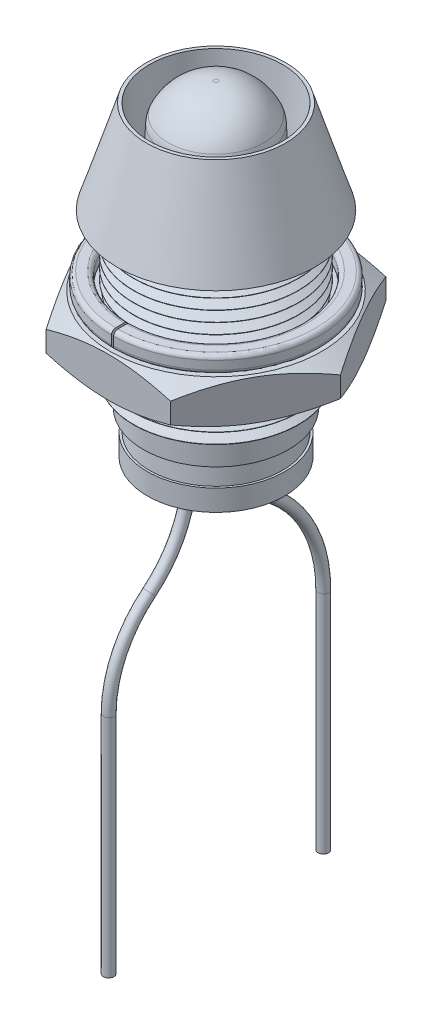
from build123d import *

# Parameters (mm, degrees)
LPATTERN1_COUNT       = 14
LPATTERN1_PITCH       = 0.5
SKETCH7_R             = 3.65
BOSS_EXTRUDE1_DEPTH   = 2
SKETCH9_R             = 4.9
SKETCH9_R_2           = 4.1
BOSS_EXTRUDE2_DEPTH   = 0.8
FILLET1_R             = 0.2
CUT_EXTRUDE4_START    = -2.8
SKETCH10_W            = 0.1
SKETCH10_H            = 2
CUT_EXTRUDE4_DEPTH    = 2.8
SKETCH12_R            = 2.45
CUT_EXTRUDE5_DEPTH    = 4.8
SKETCH13_W            = 0.8
SKETCH13_H            = 0.8
CUT_EXTRUDE6_DEPTH    = 2
SKETCH14_R            = 0.75
CUT_EXTRUDE7_DEPTH    = 0.1
CUT_EXTRUDE9_DEPTH    = 0.01
CUT_EXTRUDE8_DEPTH    = 1.2
SKETCH_WIRE_PROFILE_R = 0.25


with BuildPart() as part:
    # Sketch1 → Revolve1 (revolve)
    with BuildSketch(Plane.XY, mode=Mode.PRIVATE) as revolve1_sk:
        Polygon((0, 0), (0, 12.5), (3.3, 12.5), (4.68, 8.1), (3.9, 8.1), (3.9, 1), (3.44, 1), (3.44, 0), align=None)
    revolve(revolve1_sk.sketch.rotate(Axis((0, 0, 0), (0, 1, 0)), 90), axis=Axis((0, 0, 0), (0, 1, 0)))

    # Sketch6 → Cut-Revolve2 (revolve, cut)
    with BuildSketch(Plane.XY, mode=Mode.PRIVATE) as cut_revolve2_sk:
        Polygon((0, 0), (0, 12.5), (3.15, 12.5), (2.65, 5.8), (3.05, 5.8), (3.05, 0), align=None)
    revolve(cut_revolve2_sk.sketch.rotate(Axis((0, 0, 0), (0, 1, 0)), 90), axis=Axis((0, 0, 0), (0, 1, 0)), mode=Mode.SUBTRACT)

    # Sketch5 → Cut-Revolve1 (revolve, cut)
    with BuildSketch(Plane.XY, mode=Mode.PRIVATE) as cut_revolve1_sk:
        Polygon((4.413012702, 1.25), (4.413012702, 0.75), (3.913012702, 0.75), (3.48, 1), (3.913012702, 1.25), align=None)
    cut_revolve1 = revolve(cut_revolve1_sk.sketch.rotate(Axis((0, 0, 0), (0, 1, 0)), 90), axis=Axis((0, 0, 0), (0, 1, 0)), mode=Mode.SUBTRACT)

    # LPattern1: Cut-Revolve1 ×14
    with Locations(*[(0, i * LPATTERN1_PITCH, 0) for i in range(1, LPATTERN1_COUNT)]):
        add(cut_revolve1, mode=Mode.SUBTRACT)


with BuildPart() as body_2:
    # Sketch7 → Boss-Extrude1 (new body)
    with BuildSketch(Plane(origin=(0, 4.8, 0), x_dir=(-1, 0, 0), z_dir=(0, -1, 0))):
        Polygon((-5.888972746, 0), (-2.944486373, -5.1), (2.944486373, -5.1), (5.888972746, 0), (2.944486373, 5.1), (-2.944486373, 5.1), align=None)
        with Locations(Location((0, 0, 0), (0, 0, 90))):
            Circle(SKETCH7_R, mode=Mode.SUBTRACT)
    extrude(amount=BOSS_EXTRUDE1_DEPTH)

    # Sketch8 → Cut-Revolve3 (revolve, cut)
    with BuildSketch(Plane.XY, mode=Mode.PRIVATE) as cut_revolve3_sk:
        Polygon((5, 4.8), (5.888972746, 4.8), (5.888972746, 4.286751346), align=None)
        Polygon((5, 2.8), (5.888972746, 2.8), (5.888972746, 3.313248654), align=None)
    revolve(cut_revolve3_sk.sketch.rotate(Axis((0, 2.8, 0), (0, 1, 0)), 299.999999974), axis=Axis((0, 2.8, 0), (0, 1, 0)), mode=Mode.SUBTRACT)


with BuildPart() as body_3:
    # Sketch9 → Boss-Extrude2 (new body)
    with BuildSketch(Plane(origin=(0, 4.8, 0), x_dir=(1, 0, 0), z_dir=(0, 1, 0))):
        with Locations(Location((0, 0, 0), (0, 0, 270))):
            Circle(SKETCH9_R)
        with Locations(Location((0, 0, 0), (0, 0, 270))):
            Circle(SKETCH9_R_2, mode=Mode.SUBTRACT)
    extrude(amount=BOSS_EXTRUDE2_DEPTH)

    # Fillet1
    fillet1_edges = [body_3.edges().sort_by_distance(p)[0] for p in [
        (0, 4.8, -4.9),
        (0, 5.6, -4.9),
        (0, 4.8, -4.1),
        (0, 5.6, -4.1),
    ]]
    fillet(fillet1_edges, radius=FILLET1_R)

    # Sketch10 → Cut-Extrude4 (cut)
    with BuildSketch(Plane(origin=(0, 5.6, 0), x_dir=(1, 0, 0), z_dir=(0, 1, 0)).offset(CUT_EXTRUDE4_START)):
        with Locations((0, -4.5)):
            Rectangle(SKETCH10_W, SKETCH10_H)
    extrude(amount=CUT_EXTRUDE4_DEPTH, mode=Mode.SUBTRACT)


with BuildPart() as body_4:
    # Sketch11 → Revolve2 (revolve)
    with BuildSketch(Plane.XY, mode=Mode.PRIVATE) as revolve2_sk:
        Polygon((0, 4.8), (0, -2), (3.25, -2), (3.25, -1), (3.15, -1), (2.8, 4.8), align=None)
    revolve(revolve2_sk.sketch.rotate(Axis((0, 4.8, 0), (0, 1, 0)), 90), axis=Axis((0, 4.8, 0), (0, 1, 0)))

    # Sketch12 → Cut-Extrude5 (cut)
    with BuildSketch(Plane(origin=(0, 4.8, 0), x_dir=(1, 0, 0), z_dir=(0, 1, 0))):
        with Locations(Location((0, 0, 0), (0, 0, 270))):
            Circle(SKETCH12_R)
    extrude(amount=-CUT_EXTRUDE5_DEPTH, mode=Mode.SUBTRACT)

    # Sketch13 → Cut-Extrude6 (cut)
    with BuildSketch(Plane(origin=(0, 0, 0), x_dir=(1, 0, 0), z_dir=(0, 1, 0))):
        with Locations((0, 1.27)):
            Rectangle(SKETCH13_W, SKETCH13_H)
        with Locations((0, -1.27)):
            Rectangle(SKETCH13_W, SKETCH13_H)
    extrude(amount=-CUT_EXTRUDE6_DEPTH, mode=Mode.SUBTRACT)

    # Sketch14 → Cut-Extrude7 (cut)
    with BuildSketch(Plane.XZ.offset(2)):
        with Locations(Location((0, -1.27, 0), (0, 0, 270))):
            Circle(SKETCH14_R)
        with Locations(Location((0, 1.27, 0), (0, 0, 270))):
            Circle(SKETCH14_R)
    extrude(amount=-CUT_EXTRUDE7_DEPTH, mode=Mode.SUBTRACT)

    # Sketch21 → Cut-Extrude9 (cut)
    with BuildSketch(Plane.XZ.offset(2)):
        with BuildLine():
            add(Edge.make_bspline(
                [(0.364705882, 2.263786765), (0.365912746, 2.260307351), (0.368162564, 2.253821082), (0.370714357, 2.24445712), (0.372758311, 2.236319514), (0.374151689, 2.229223622), (0.374675847, 2.223078316), (0.373899912, 2.217778193), (0.372316679, 2.21309534), (0.369179602, 2.20933953), (0.364961324, 2.206278709), (0.35935951, 2.20418994), (0.352616544, 2.202313423), (0.344448609, 2.201319849), (0.33486625, 2.200924205), (0.323782624, 2.200230338), (0.31096711, 2.200209211), (0.301899116, 2.200072809), (0.297058824, 2.2)],
                knots=[0, 0, 0, 0, 1.351975101, 2.52033068, 3.562719996, 4.432170766, 5.176088948, 5.812532786, 6.389296298, 6.965620705, 7.577732788, 8.283941723, 9.146375963, 10.145613058, 11.295182858, 12.669444765, 14.222224263, 16, 16, 16, 16], degree=3))
            add(Edge.make_bspline(
                [(0.297058824, 2.2), (0.292095654, 2.199988185), (0.282720354, 2.199965866), (0.269543114, 2.200112253), (0.258088748, 2.200552893), (0.245808258, 2.200889505), (0.233505333, 2.202060288), (0.221675289, 2.203990326), (0.213185608, 2.207223602), (0.207403537, 2.211992232), (0.204102868, 2.218299147), (0.202511149, 2.222774813), (0.201654412, 2.225183824)],
                knots=[0, 0, 0, 0, 1.402041787, 2.648421349, 3.722147351, 4.640185661, 6.117966101, 7.211050041, 8.017924191, 8.656254393, 9.276733986, 10, 10, 10, 10], degree=3))
            Line((0.201654412, 2.225183824), (0.152757353, 2.376470588))
            Line((0.152757353, 2.376470588), (-0.149080882, 2.376470588))
            Line((-0.149080882, 2.376470588), (-0.195404412, 2.229411765))
            add(Edge.make_bspline(
                [(-0.195404412, 2.229411765), (-0.196242787, 2.226750378), (-0.197839297, 2.221682321), (-0.201464604, 2.214682127), (-0.20730362, 2.209161907), (-0.215536329, 2.205017369), (-0.226905918, 2.202530019), (-0.241791458, 2.200721443), (-0.261091529, 2.200310501), (-0.275430667, 2.20011142), (-0.283455882, 2.2)],
                knots=[0, 0, 0, 0, 0.662368552, 1.261342941, 1.847645799, 2.537239812, 3.42265718, 4.595262896, 6.094463672, 8, 8, 8, 8], degree=3))
            add(Edge.make_bspline(
                [(-0.283455882, 2.2), (-0.287929123, 2.200046118), (-0.296386898, 2.200133315), (-0.308338926, 2.200486338), (-0.318757062, 2.201043913), (-0.327736966, 2.201666302), (-0.335267923, 2.202885446), (-0.341601074, 2.204740787), (-0.346721123, 2.20718425), (-0.351990933, 2.21149302), (-0.355485865, 2.219845517), (-0.355080161, 2.232128231), (-0.351199376, 2.247349326), (-0.347617715, 2.258662904), (-0.345588235, 2.265073529)],
                knots=[0, 0, 0, 0, 1.279822224, 2.419822313, 3.420424811, 4.264789446, 4.993926375, 5.598399463, 6.14718048, 6.607326483, 7.517039103, 8.604050794, 10.075749779, 12, 12, 12, 12], degree=3))
            Line((-0.345588235, 2.265073529), (-0.103676471, 2.968198529))
            add(Edge.make_bspline(
                [(-0.103676471, 2.968198529), (-0.102412485, 2.971358756), (-0.100075054, 2.977202818), (-0.09541878, 2.985181178), (-0.088433792, 2.991412616), (-0.078272996, 2.995260608), (-0.06498922, 2.998172051), (-0.051300923, 2.999061745), (-0.03811427, 2.999453526), (-0.026166715, 2.999878192), (-0.012684311, 3.000036507), (-0.003186298, 3.000012631), (0.001838235, 3)],
                knots=[0, 0, 0, 0, 0.856868194, 1.584566637, 2.305859304, 3.162727498, 4.285524966, 5.725550839, 6.605441018, 7.608682037, 8.734971556, 10, 10, 10, 10], degree=3))
            add(Edge.make_bspline(
                [(0.001838235, 3), (0.007598061, 3.000012106), (0.018566601, 3.000035161), (0.034070789, 2.999881573), (0.047734495, 2.999457841), (0.062634251, 2.999054875), (0.077907199, 2.99820735), (0.092731659, 2.995274452), (0.103894426, 2.991351452), (0.111672454, 2.984840238), (0.116729804, 2.976253618), (0.118993121, 2.969839091), (0.120220588, 2.966360294)],
                knots=[0, 0, 0, 0, 1.298203691, 2.47219252, 3.494555852, 4.378870695, 5.833194716, 6.932857721, 7.781737059, 8.467837287, 9.169060755, 10, 10, 10, 10], degree=3))
            Line((0.120220588, 2.966360294), (0.364705882, 2.263786765))
        make_face()
        Polygon((0, 2.850551471), (-0.108455882, 2.505882353), (0.111029412, 2.505882353), align=None, mode=Mode.SUBTRACT)
        with BuildLine():
            add(Edge.make_bspline(
                [(0.3, -2.867095588), (0.299993515, -2.871754197), (0.299981559, -2.880343159), (0.299189628, -2.892237559), (0.298194291, -2.902263242), (0.296560207, -2.910709062), (0.294311649, -2.91784639), (0.291469889, -2.924384306), (0.286900742, -2.930790742), (0.282277813, -2.936829517), (0.277129018, -2.942580139), (0.271263229, -2.947461292), (0.263952333, -2.953164198), (0.25153147, -2.961732187), (0.232938326, -2.97255412), (0.207275338, -2.98494378), (0.177197177, -2.995607411), (0.143411817, -3.004640204), (0.105968809, -3.010697146), (0.079864935, -3.011400718), (0.066360294, -3.011764706)],
                knots=[0, 0, 0, 0, 0.817477301, 1.507162764, 2.091525744, 2.585101367, 3.013698999, 3.403571139, 3.830139735, 4.389521305, 4.739690108, 5.181838318, 5.726127005, 6.367582384, 7.828489835, 9.497787956, 11.362220851, 13.420571043, 15.630867283, 18, 18, 18, 18], degree=3))
            add(Edge.make_bspline(
                [(0.066360294, -3.011764706), (0.053050678, -3.011431824), (0.027085188, -3.010782412), (-0.010957693, -3.006147652), (-0.04697827, -2.998307844), (-0.080986064, -2.987255413), (-0.112838542, -2.973152262), (-0.142151926, -2.955517565), (-0.169231656, -2.935078063), (-0.193619479, -2.911328295), (-0.215519764, -2.884512322), (-0.234353168, -2.854309523), (-0.250845991, -2.821232106), (-0.264345132, -2.784978006), (-0.275337757, -2.745727259), (-0.282510375, -2.703267113), (-0.287590776, -2.657904475), (-0.28801608, -2.626608668), (-0.288235294, -2.610477941)],
                knots=[0, 0, 0, 0, 1.04884528, 2.046173269, 3.015214692, 3.949843553, 4.859908047, 5.754373417, 6.640074381, 7.528023805, 8.430832778, 9.361986752, 10.3273752, 11.339120453, 12.406480085, 13.534714217, 14.729323304, 16, 16, 16, 16], degree=3))
            add(Edge.make_bspline(
                [(-0.288235294, -2.610477941), (-0.287955309, -2.593980094), (-0.287410533, -2.561879679), (-0.28210292, -2.515170116), (-0.273793023, -2.471298519), (-0.262025183, -2.430313676), (-0.247124796, -2.392368034), (-0.229479255, -2.357408685), (-0.209039287, -2.325665743), (-0.18593263, -2.297045956), (-0.160051052, -2.271889768), (-0.131983798, -2.249541183), (-0.101261916, -2.230751709), (-0.068240175, -2.215340605), (-0.033202923, -2.203128663), (0.003726296, -2.194648807), (0.042352216, -2.189028761), (0.068729578, -2.188503116), (0.082169118, -2.188235294)],
                knots=[0, 0, 0, 0, 1.247364886, 2.427039795, 3.55045214, 4.621200906, 5.64704897, 6.629476075, 7.578181143, 8.497404382, 9.405200954, 10.302706402, 11.205651615, 12.122019826, 13.054178336, 14.006318378, 14.984198529, 16, 16, 16, 16], degree=3))
            add(Edge.make_bspline(
                [(0.082169118, -2.188235294), (0.093090756, -2.18851722), (0.114588335, -2.189072147), (0.146005037, -2.193455865), (0.175533041, -2.200007032), (0.202902782, -2.208350164), (0.227906339, -2.21788779), (0.246669917, -2.227422665), (0.25990831, -2.235181965), (0.268175123, -2.240366189), (0.274734128, -2.24538511), (0.280900965, -2.251150971), (0.286532001, -2.257291934), (0.29148756, -2.26414519), (0.294461394, -2.271399119), (0.296513746, -2.279576356), (0.298205001, -2.289346289), (0.299182812, -2.300842262), (0.299990979, -2.314571961), (0.299996803, -2.324508051), (0.3, -2.329963235)],
                knots=[0, 0, 0, 0, 1.99247574, 3.921884623, 5.777623321, 7.507428254, 9.139636718, 10.654923546, 11.341526285, 11.940176233, 12.43448366, 12.845959356, 13.479321404, 13.953882042, 14.379694984, 14.900487377, 15.490617055, 16.187164526, 17.004703962, 18, 18, 18, 18], degree=3))
            add(Edge.make_bspline(
                [(0.3, -2.329963235), (0.299922224, -2.335846416), (0.299778713, -2.346701901), (0.298952011, -2.361626981), (0.297411295, -2.373891864), (0.295038111, -2.383646546), (0.291440351, -2.390906865), (0.287416316, -2.39612246), (0.28256478, -2.399498633), (0.278966621, -2.399835269), (0.277205882, -2.4)],
                knots=[0, 0, 0, 0, 1.773747753, 3.272870731, 4.503340964, 5.498117188, 6.282928042, 6.926292104, 7.474587188, 8, 8, 8, 8], degree=3))
            add(Edge.make_bspline(
                [(0.277205882, -2.4), (0.275535494, -2.39982508), (0.271909631, -2.399445385), (0.26635245, -2.39720343), (0.260173096, -2.393832874), (0.25075734, -2.386842956), (0.236633446, -2.376527873), (0.216229113, -2.363863101), (0.191718223, -2.350888063), (0.168126869, -2.341611029), (0.147006165, -2.335314784), (0.129169649, -2.33181279), (0.109848245, -2.329852702), (0.096450565, -2.329562065), (0.089522059, -2.329411765)],
                knots=[0, 0, 0, 0, 0.294660949, 0.639611878, 1.045415135, 1.533607636, 2.701972583, 4.127801724, 5.759893443, 7.582166846, 8.583129585, 9.639604504, 10.779339718, 12, 12, 12, 12], degree=3))
            add(Edge.make_bspline(
                [(0.089522059, -2.329411765), (0.081782918, -2.329571813), (0.066700963, -2.329883713), (0.044784126, -2.333829392), (0.024018285, -2.339540575), (0.004655044, -2.348091071), (-0.013231119, -2.358898523), (-0.029999013, -2.371449676), (-0.045261269, -2.386244506), (-0.059112995, -2.403090519), (-0.071381276, -2.421855436), (-0.082116851, -2.442494946), (-0.091288684, -2.464950084), (-0.098770613, -2.489262857), (-0.10461641, -2.515263261), (-0.108861592, -2.542895932), (-0.111161193, -2.572142269), (-0.111560461, -2.59215315), (-0.111764706, -2.602389706)],
                knots=[0, 0, 0, 0, 0.972080817, 1.89438068, 2.79201181, 3.675405302, 4.546341706, 5.415605955, 6.303960111, 7.212703157, 8.153143135, 9.118265211, 10.13431466, 11.199471373, 12.313676298, 13.483115176, 14.712488772, 16, 16, 16, 16], degree=3))
            add(Edge.make_bspline(
                [(-0.111764706, -2.602389706), (-0.111607969, -2.613548769), (-0.111305174, -2.635106632), (-0.108433763, -2.666283439), (-0.104207054, -2.695194456), (-0.097900768, -2.721791767), (-0.090120918, -2.746146473), (-0.080437184, -2.768183018), (-0.069527584, -2.788118005), (-0.056928858, -2.805761432), (-0.04283771, -2.821174461), (-0.027315249, -2.834469993), (-0.010468326, -2.845752018), (0.007681859, -2.855085417), (0.027260103, -2.861985816), (0.048033081, -2.866894859), (0.069932034, -2.87018834), (0.084975388, -2.870453176), (0.092647059, -2.870588235)],
                knots=[0, 0, 0, 0, 1.39820726, 2.701155002, 3.920851914, 5.057115416, 6.123247462, 7.120555937, 8.069346848, 8.966541661, 9.830790757, 10.680415293, 11.521739042, 12.366630257, 13.231390995, 14.116141633, 15.039287353, 16, 16, 16, 16], degree=3))
            add(Edge.make_bspline(
                [(0.092647059, -2.870588235), (0.099576206, -2.870442672), (0.112914179, -2.870162476), (0.132226543, -2.868146161), (0.150019855, -2.864735295), (0.171227391, -2.858342602), (0.194682203, -2.848761039), (0.219150068, -2.83579162), (0.239407498, -2.82313962), (0.253711128, -2.813205225), (0.263105229, -2.806147754), (0.269211592, -2.802896707), (0.27441492, -2.800585733), (0.277740794, -2.800180982), (0.279227941, -2.8)],
                knots=[0, 0, 0, 0, 1.227460679, 2.362749415, 3.435761231, 4.43188492, 6.282452832, 7.914022885, 9.332840532, 10.51031958, 11.001231841, 11.409295861, 11.73586979, 12, 12, 12, 12], degree=3))
            add(Edge.make_bspline(
                [(0.279227941, -2.8), (0.281080841, -2.800066063), (0.284475071, -2.800187081), (0.289303379, -2.802130109), (0.292846664, -2.806425859), (0.295459421, -2.812788763), (0.297629573, -2.821639919), (0.298931011, -2.833546699), (0.29981862, -2.849005719), (0.299934856, -2.860598488), (0.3, -2.867095588)],
                knots=[0, 0, 0, 0, 0.574868731, 1.05307148, 1.566117152, 2.257286433, 3.182192672, 4.393071976, 5.978517896, 8, 8, 8, 8], degree=3))
        make_face()
    extrude(amount=-CUT_EXTRUDE9_DEPTH, mode=Mode.SUBTRACT)


with BuildPart() as body_5:
    # Sketch15 → Revolve3 (revolve)
    with BuildSketch(Plane.XY, mode=Mode.PRIVATE) as revolve3_sk:
        with BuildLine():
            Line((0, 4.8), (0, 13.4))
            Line((0, 13.4), (0.1, 13.4))
            ThreePointArc((0.1, 13.4), (1.391832408, 13.019278797), (2.270716423, 11.998816896))
            ThreePointArc((2.270716423, 11.998816896), (2.33150121, 11.821726944), (2.358209363, 11.636410145))
            ThreePointArc((2.358209363, 11.636410145), (2.457047318, 8.96901864), (2.49, 6.3))
            Line((2.49, 6.3), (2.49, 6))
            Line((2.49, 6), (2.8, 6))
            Line((2.8, 6), (2.8, 4.8))
            Line((2.8, 4.8), (0, 4.8))
        make_face()
    revolve(revolve3_sk.sketch.rotate(Axis((0, 4.8, 0), (0, 1, 0)), 90), axis=Axis((0, 4.8, 0), (0, 1, 0)))

    # Sketch17 → Cut-Extrude8 (cut)
    with BuildSketch(Plane(origin=(0, 6, 0), x_dir=(1, 0, 0), z_dir=(0, 1, 0))):
        with BuildLine():
            Line((-1.220491704, 2.52), (1.220491704, 2.52))
            ThreePointArc((1.220491704, 2.52), (0, 2.8), (-1.220491704, 2.52))
        make_face()
    extrude(amount=-CUT_EXTRUDE8_DEPTH, mode=Mode.SUBTRACT)


with BuildPart() as body_6:
    # ADJUST LED WIRES: sweep along a path in Sketch Wire Path
    with BuildLine(Plane(origin=(0, 0, 0), x_dir=(0, 0, -1), z_dir=(1, 0, 0))) as adjust_led_wires_path:
        Line((-5.08, -20.67045335), (-5.08, -10))
        ThreePointArc((-5.08, -10), (-4.579432337, -7.784767224), (-3.175, -6))
        ThreePointArc((-3.175, -6), (-1.770567663, -4.215232776), (-1.27, -2))
        Line((-1.27, -2), (-1.27, 5.4))
        Line((-1.27, 5.4), (0, 5.4))
        Line((0, 5.4), (1.27, 5.4))
        Line((1.27, 5.4), (1.27, -2))
        ThreePointArc((1.27, -2), (1.645425747, -3.661424582), (2.69875, -5))
        ThreePointArc((2.69875, -5), (4.454290421, -7.230959031), (5.08, -10))
        Line((5.08, -10), (5.08, -20.67045335))
    # Sketch Wire Profile → ADJUST LED WIRES (sweep)
    with BuildSketch(Plane.XY):
        with Locations((0, 5.4)):
            Circle(SKETCH_WIRE_PROFILE_R)
    sweep(path=adjust_led_wires_path.line, transition=Transition.RIGHT)


solid = Compound([part.part, body_2.part, body_3.part, body_4.part, body_5.part, body_6.part])
